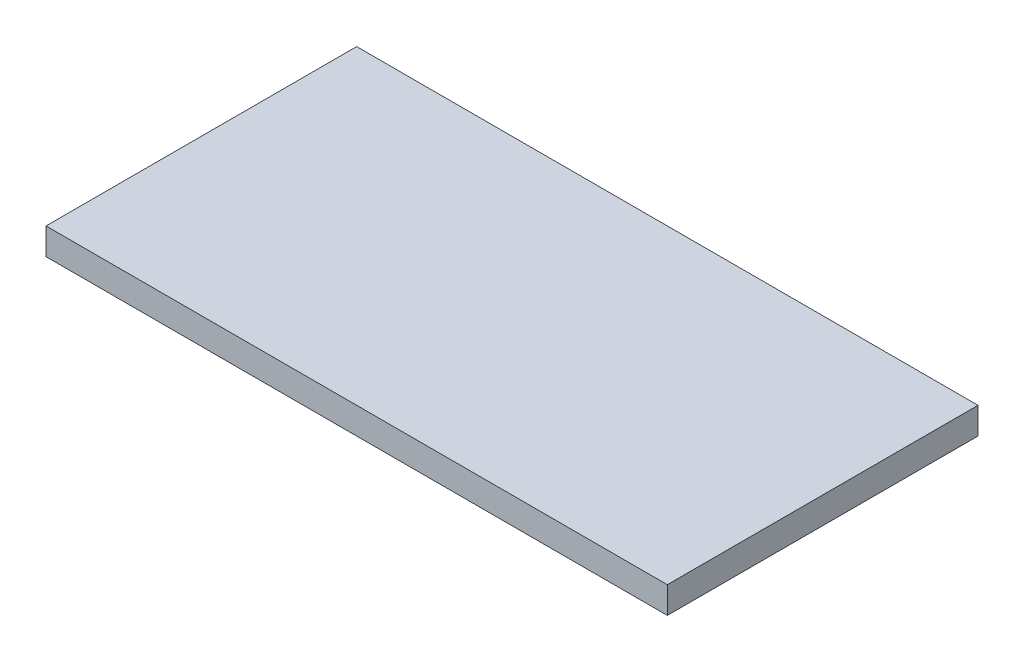
from build123d import *

# Parameters (mm, degrees)
SKETCH_1_W      = 700
SKETCH_1_H      = 350
EXTRUDE_1_DEPTH = 30


with BuildPart() as part:
    # Эскиз1 → Бобышка-Вытянуть1 (new body)
    with BuildSketch(Plane(origin=(0, 0, 0), x_dir=(1, 0, 0), z_dir=(0, 1, 0))):
        with Locations((350, 175)):
            Rectangle(SKETCH_1_W, SKETCH_1_H)
    extrude(amount=EXTRUDE_1_DEPTH)


solid = part.part
